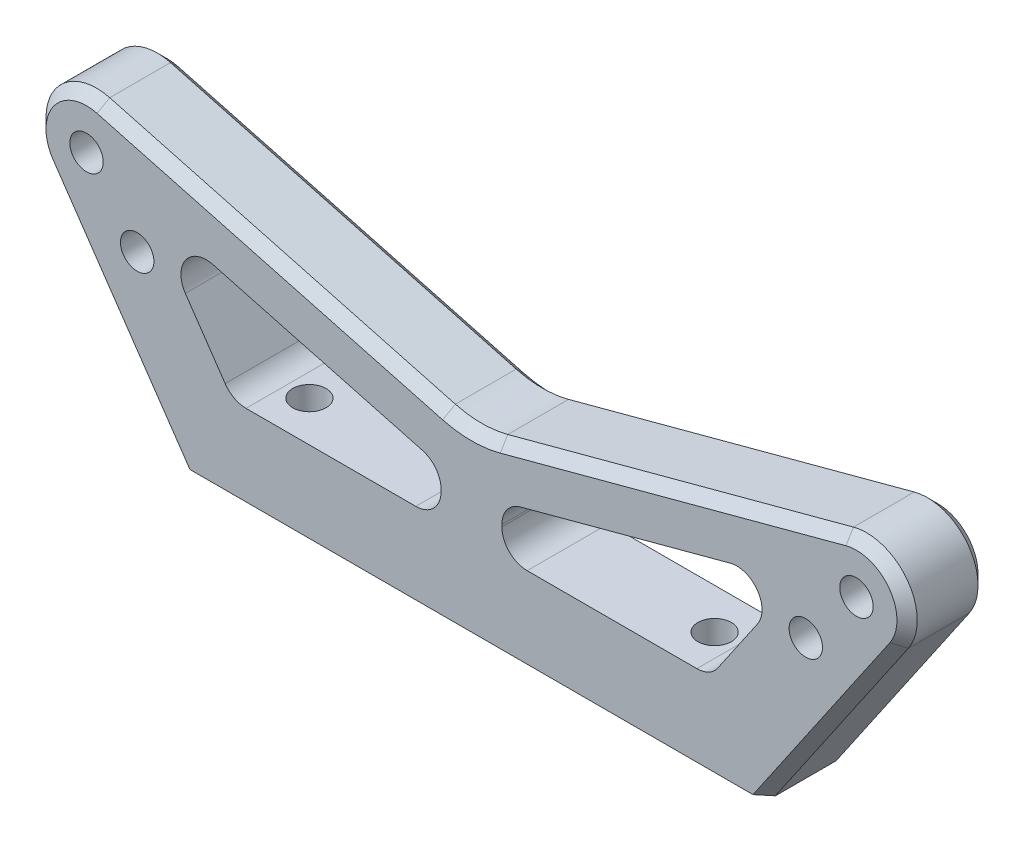
from build123d import *

# Parameters (mm, degrees)
BOSS_EXTRU_1_DEPTH      = 4
TROU_TARAUD_M42_D       = 3.3
TROU_TARAUD_M43_D       = 3.3
TROU_TARAUD_M43_DEPTH   = 15.5
TROU_TARAUD_M43_TIP     = 0.991420021
CONG_1_R                = 10
ENL_V_START             = -9
ENL_V_MAT_EXTRU_1_DEPTH = 10
CHANFREIN1_SIZE         = 1


with BuildPart() as part:
    # Esquisse1 → Boss.-Extru.1 (new body, symmetric)
    with BuildSketch(Plane.XY):
        with BuildLine():
            Line((-29, 0), (29, 0))
            Line((29, 0), (42.125962847, 19.175742472))
            ThreePointArc((42.125962847, 19.175742472), (42.080485732, 24.889573705), (36.705904774, 26.829629131))
            Line((36.705904774, 26.829629131), (0, 16.99431159))
            Line((0, 16.99431159), (-36.705904774, 26.829629131))
            ThreePointArc((-36.705904774, 26.829629131), (-42.080485732, 24.889573705), (-42.125962847, 19.175742472))
            Line((-42.125962847, 19.175742472), (-29, 0))
        make_face()
    extrude(amount=BOSS_EXTRU_1_DEPTH, both=True)

    # Trou taraudé M42 (through all)
    with Locations(Plane.XY.offset(4)):
        with Locations((-38, 22), (38, 22), (-33, 16), (33, 16)):
            Hole(TROU_TARAUD_M42_D / 2)

    # Trou taraudé M43
    with Locations(Plane(origin=(0, 0, 0), x_dir=(-1, 0, 0), z_dir=(0, -1, 0))):
        with Locations((20, 0), (-20, 0), (0, -0.5)):
            Hole(TROU_TARAUD_M43_D / 2, depth=TROU_TARAUD_M43_DEPTH)
            with Locations((0, 0, -(TROU_TARAUD_M43_DEPTH + TROU_TARAUD_M43_TIP / 2))):  # 118° drill point
                Cone(0, TROU_TARAUD_M43_D / 2, TROU_TARAUD_M43_TIP, mode=Mode.SUBTRACT)

    # Congé1
    cong_1_edges = [part.edges().sort_by_distance(p)[0] for p in [
        (0, 16.99431159, 0),
    ]]
    fillet(cong_1_edges, radius=CONG_1_R)

    # Esquisse8 → Enlèv. mat.-Extru.1 (cut)
    with BuildSketch(Plane.XY.offset(4).offset(ENL_V_START)):
        with BuildLine():
            Line((-3, 10.703460795), (-3, 10.5))
            ThreePointArc((-3, 10.5), (-3.732233047, 8.732233047), (-5.5, 8))
            Line((-5.5, 8), (-22.251200511, 8))
            ThreePointArc((-22.251200511, 8), (-23.417321879, 8.288629168), (-24.314181934, 9.087871236))
            Line((-24.314181934, 9.087871236), (-28.247222943, 14.833657842))
            ThreePointArc((-28.247222943, 14.833657842), (-28.224484386, 17.690573459), (-25.537193907, 18.660601172))
            Line((-25.537193907, 18.660601172), (-4.852952387, 13.118275361))
            ThreePointArc((-4.852952387, 13.118275361), (-3.516616649, 12.225364367), (-3, 10.703460795))
        make_face()
    enl_v_mat_extru_1 = extrude(amount=ENL_V_MAT_EXTRU_1_DEPTH, mode=Mode.SUBTRACT)

    # Symétrie1: Enlèv. mat.-Extru.1 across plane
    add(enl_v_mat_extru_1.mirror(Plane(origin=(0, 0, 0), x_dir=(0, 0, 1), z_dir=(1, 0, 0))), mode=Mode.SUBTRACT)

    # Chanfrein1
    chanfrein1_edges = [part.edges().sort_by_distance(p)[0] for p in [
        (-35.562981423, 9.587871236, -4),
        (-42.080485732, 24.889573705, 4),
        (-42.080485732, 24.889573705, -4),
        (-19.647047613, 22.258722131, -4),
        (-35.562981423, 9.587871236, 4),
        (35.562981423, 9.587871236, 4),
        (42.080485732, 24.889573705, 4),
        (-19.647047613, 22.258722131, 4),
        (19.647047613, 22.258722131, -4),
        (19.647047613, 22.258722131, 4),
        (0, 17.347073394, -4),
        (0, 17.347073394, 4),
        (42.080485732, 24.889573705, -4),
        (35.562981423, 9.587871236, -4),
    ]]
    chamfer(chanfrein1_edges, length=CHANFREIN1_SIZE)


solid = part.part
